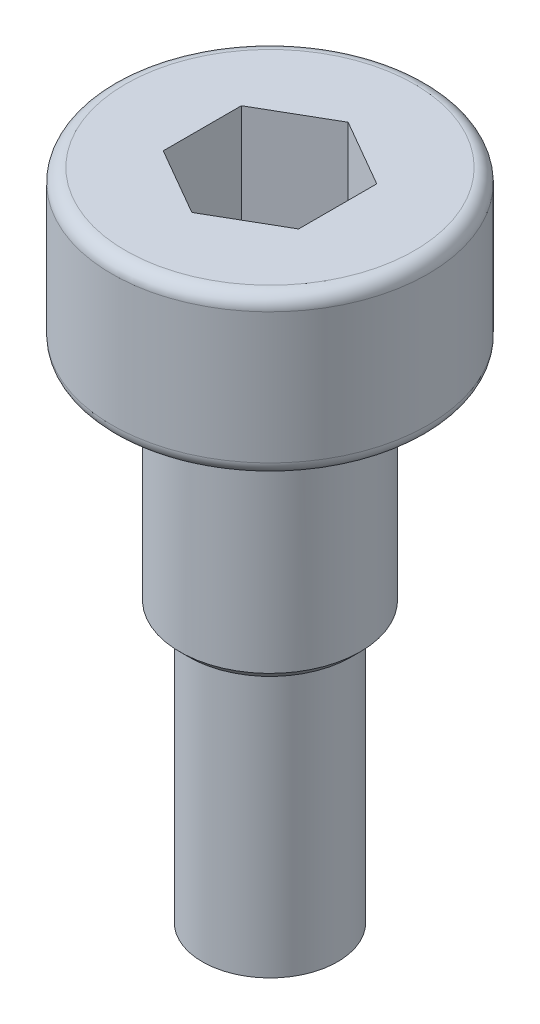
from build123d import *

# Parameters (mm, degrees)
FILLET1_R          = 0.3
CUT_EXTRUDE1_DEPTH = 2.4
CHAMFER1_SIZE      = 0.2


with BuildPart() as part:
    # Sketch1 → Revolve1 (revolve)
    with BuildSketch(Plane.XY):
        Polygon((0, 3.5), (-3.5, 3.5), (-3.5, 0), (-2, 0), (-2, -5), (-1.5, -5), (-1.5, -11), (0, -11), align=None)
    revolve(axis=Axis((0, 3.5, 0), (0, -1, 0)))

    # Fillet1
    fillet1_edges = [part.edges().sort_by_distance(p)[0] for p in [
        (3.5, 0, 0),
        (3.5, 3.5, 0),
    ]]
    fillet(fillet1_edges, radius=FILLET1_R)

    # Sketch2 → Cut-Extrude1 (cut)
    with BuildSketch(Plane(origin=(0, 3.5, 0), x_dir=(1, 0, 0), z_dir=(0, 1, 0))):
        Polygon((1.5, 0.866025404), (0, 1.732050808), (-1.5, 0.866025404), (-1.5, -0.866025404), (0, -1.732050808), (1.5, -0.866025404), align=None)
    extrude(amount=-CUT_EXTRUDE1_DEPTH, mode=Mode.SUBTRACT)

    # Chamfer1
    chamfer1_edges = [part.edges().sort_by_distance(p)[0] for p in [
        (2, -5, 0),
    ]]
    chamfer(chamfer1_edges, length=CHAMFER1_SIZE)


solid = part.part
